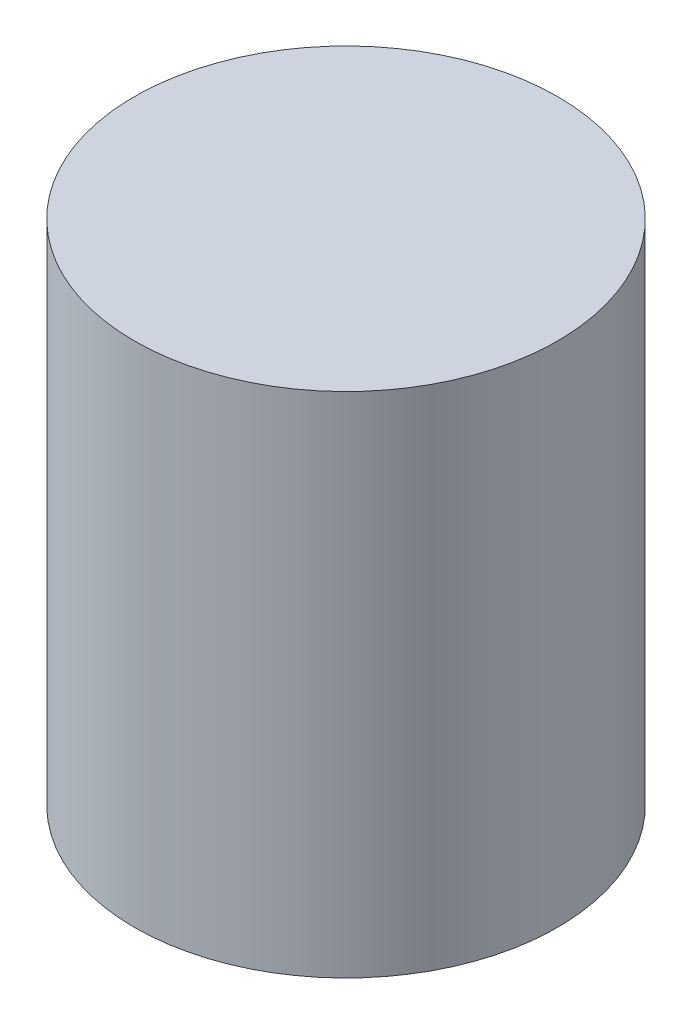
from build123d import *

# Parameters (mm, degrees)
SKETCH1_R           = 0.635
BOSS_EXTRUDE1_DEPTH = 1.524


with BuildPart() as part:
    # Sketch1 → Boss-Extrude1 (new body)
    with BuildSketch(Plane(origin=(0, 0, 0), x_dir=(1, 0, 0), z_dir=(0, 1, 0))):
        Circle(SKETCH1_R)
    extrude(amount=BOSS_EXTRUDE1_DEPTH)


solid = part.part
